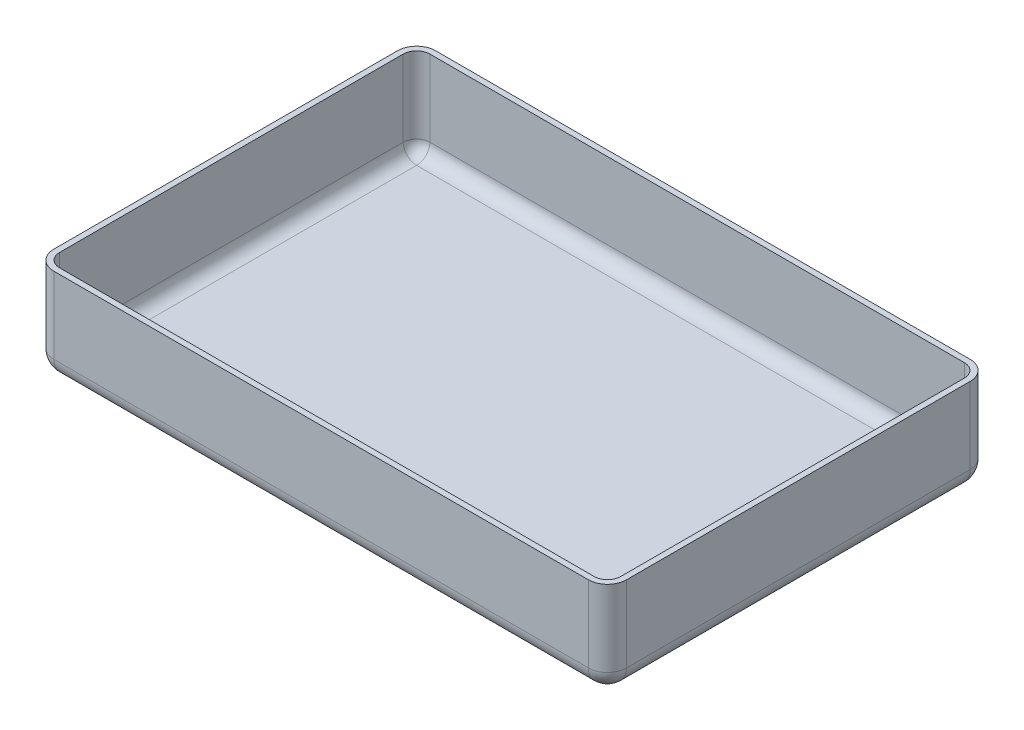
from build123d import *

# Parameters (mm, degrees)
SKETCH1_W           = 300
SKETCH1_H           = 200
BOSS_EXTRUDE1_DEPTH = 50
FILLET1_R           = 10
SHELL1_T            = -3


with BuildPart() as part:
    # Sketch1 → Boss-Extrude1 (new body)
    with BuildSketch(Plane(origin=(0, 0, 0), x_dir=(1, 0, 0), z_dir=(0, 1, 0))):
        Rectangle(SKETCH1_W, SKETCH1_H)
    extrude(amount=BOSS_EXTRUDE1_DEPTH)

    # Fillet1
    fillet1_edges = [part.edges().sort_by_distance(p)[0] for p in [
        (0, 0, -100),
        (150, 0, 0),
        (0, 0, 100),
        (-150, 0, 0),
        (-150, 25, -100),
        (150, 25, -100),
        (150, 25, 100),
        (-150, 25, 100),
    ]]
    fillet(fillet1_edges, radius=FILLET1_R)

    # Shell1
    shell1_openings = [part.faces().sort_by_distance(p)[0] for p in [
        (0, 50, 0),
    ]]
    offset(amount=SHELL1_T, openings=shell1_openings, kind=Kind.INTERSECTION)


solid = part.part
